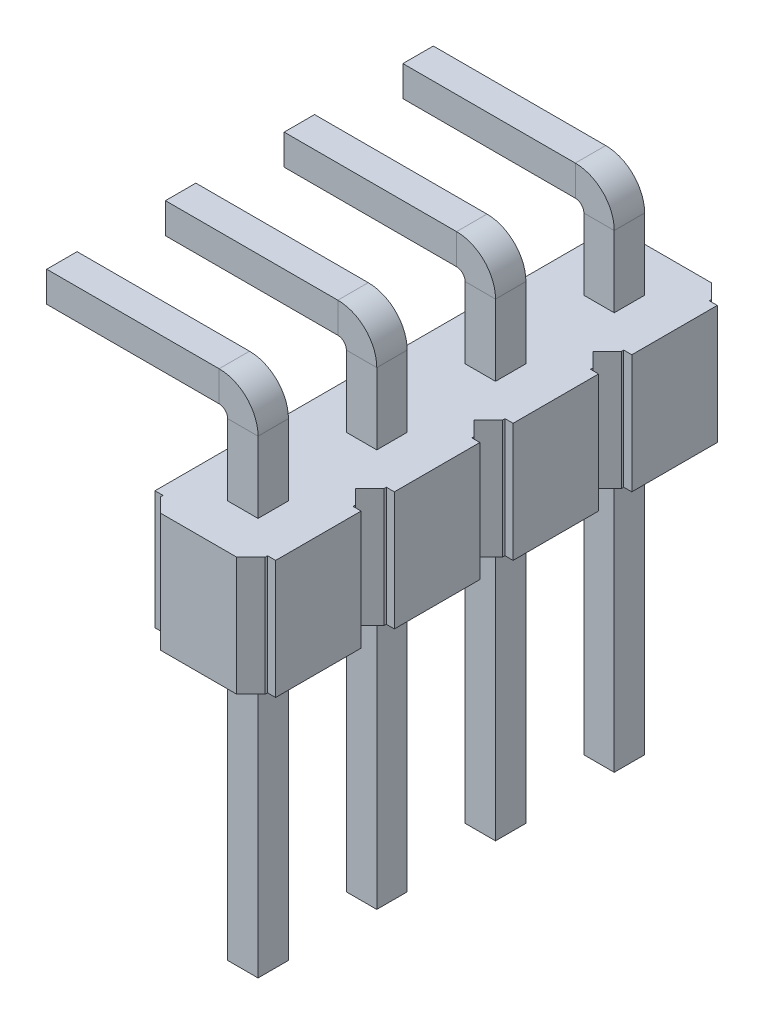
from build123d import *

# Parameters (mm, degrees)
BOSS_EXTRUDE1_DEPTH        = 2.5
SKETCH6_W                  = 0.64
SKETCH6_H                  = 0.64
CUT_EXTRUDE1_DEPTH         = 2.5
SKETCH15_W                 = 0.64
SKETCH15_H                 = 0.64
CHAMFER4_SIZE              = 0.12
LPATTERN5_COUNT            = 4
LPATTERN5_PITCH            = 2.5
CHAMFER4_OF_LPATTERN5_SIZE = 0.12


with BuildPart() as part:
    # Sketch4 → Boss-Extrude1 (new body)
    with BuildSketch(Plane(origin=(0, 0, 0), x_dir=(1, 0, 0), z_dir=(0, 1, 0))):
        Polygon((-2.37, -0.9), (-2.37, -0.95), (-2.07, -1.25), (-0.47, -1.25), (-0.17, -0.95), (-0.17, -0.9), (0, -0.9), (0, 0.9), (-0.17, 0.9), (-0.17, 0.95), (-0.47, 1.25), (-2.07, 1.25), (-2.37, 0.95), (-2.37, 0.9), (-2.54, 0.9), (-2.54, -0.9), align=None)
    boss_extrude1 = extrude(amount=BOSS_EXTRUDE1_DEPTH)

    # Sketch6 → Cut-Extrude1 (cut)
    with BuildSketch(Plane.XZ):
        with Locations((-1.27, 0)):
            Rectangle(SKETCH6_W, SKETCH6_H)
        with Locations((1.27, 0)):
            Rectangle(SKETCH6_W, SKETCH6_H)
    extrude(amount=-CUT_EXTRUDE1_DEPTH, mode=Mode.SUBTRACT)

    # Sweep1: sweep along a path in Sketch17
    with BuildLine(Plane(origin=(0, 0, 0), x_dir=(1, 0, 0), z_dir=(0, 0, -1))) as sweep1_path:
        Line((-1.27, 6), (-1.27, -4))
        ThreePointArc((-1.27, -4), (-1.416446609, -4.353553391), (-1.77, -4.5))
        Line((-1.77, -4.5), (-5.52, -4.5))
    # Sketch15 → Sweep1 (sweep)
    with BuildSketch(Plane(origin=(0, -6, 0), x_dir=(1, 0, 0), z_dir=(0, 1, 0))):
        with Locations((-1.27, 0)):
            Rectangle(SKETCH15_W, SKETCH15_H)
    sweep1 = sweep(path=sweep1_path.line)

    # Chamfer4
    chamfer4_edges = [part.edges().sort_by_distance(p)[0] for p in [
        (-0.95, -6, 0),
        (-1.59, -6, 0),
        (-1.27, -6, -0.32),
        (-1.27, -6, 0.32),
        (-5.52, 4.18, 0),
        (-5.52, 4.5, 0.32),
        (-5.52, 4.82, 0),
        (-5.52, 4.5, -0.32),
    ]]
    chamfer(chamfer4_edges, length=CHAMFER4_SIZE)

    # LPattern5: Boss-Extrude1, Sweep1 ×4
    with Locations(*[(0, 0, i * LPATTERN5_PITCH) for i in range(1, LPATTERN5_COUNT)]):
        add(boss_extrude1)
        add(sweep1)

    # Chamfer4 of LPattern5
    chamfer4_of_lpattern5_edges = [part.edges().sort_by_distance(p)[0] for p in [
        (-0.95, -6, 2.5),
        (-1.59, -6, 2.5),
        (-1.27, -6, 2.18),
        (-1.27, -6, 2.82),
        (-5.52, 4.18, 2.5),
        (-5.52, 4.5, 2.82),
        (-5.52, 4.82, 2.5),
        (-5.52, 4.5, 2.18),
        (-0.95, -6, 5),
        (-1.59, -6, 5),
        (-1.27, -6, 4.68),
        (-1.27, -6, 5.32),
        (-5.52, 4.18, 5),
        (-5.52, 4.5, 5.32),
        (-5.52, 4.82, 5),
        (-5.52, 4.5, 4.68),
        (-0.95, -6, 7.5),
        (-1.59, -6, 7.5),
        (-1.27, -6, 7.18),
        (-1.27, -6, 7.82),
        (-5.52, 4.18, 7.5),
        (-5.52, 4.5, 7.82),
        (-5.52, 4.82, 7.5),
        (-5.52, 4.5, 7.18),
    ]]
    chamfer(chamfer4_of_lpattern5_edges, length=CHAMFER4_OF_LPATTERN5_SIZE)


solid = part.part
